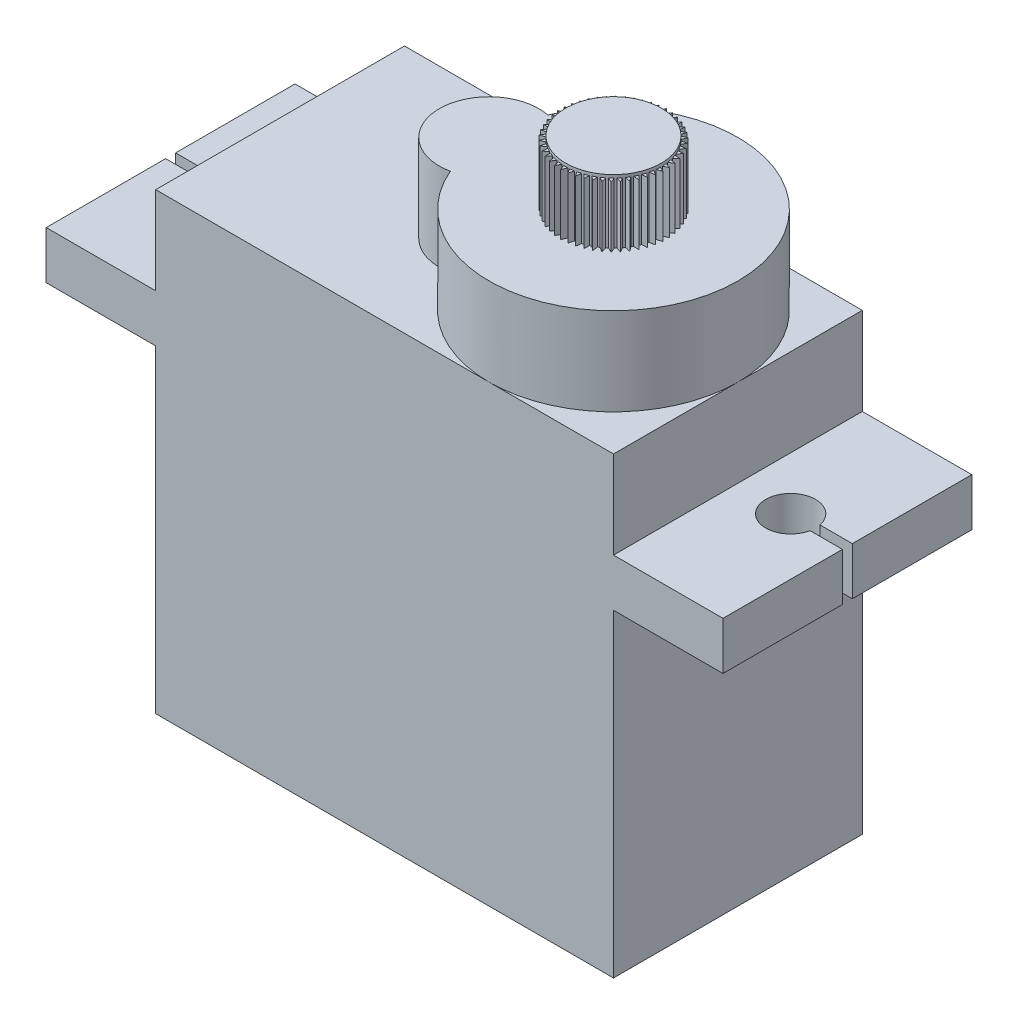
from build123d import *

# Parameters (mm, degrees)
SKETCH2_W           = 23
SKETCH2_H           = 12.5
BOSS_EXTRUDE1_DEPTH = 16
BOSS_EXTRUDE2_DEPTH = 2.4
SKETCH4_W           = 23
SKETCH4_H           = 12.5
BOSS_EXTRUDE3_DEPTH = 4.4
SKETCH5_R           = 1.25
CUT_EXTRUDE1_DEPTH  = 4.4
SKETCH6_W           = 3.848237884
SKETCH6_H           = 0.5
CUT_EXTRUDE2_DEPTH  = 4.4
SKETCH7_R           = 6.25
BOSS_EXTRUDE4_DEPTH = 4.4
SKETCH8_R           = 2.5
BOSS_EXTRUDE5_DEPTH = 4.4
SKETCH9_R           = 2.4
BOSS_EXTRUDE6_DEPTH = 3.2
BOSS_EXTRUDE7_DEPTH = 3.05
CIRPATTERN1_COUNT   = 50


with BuildPart() as part:
    # Sketch2 → Boss-Extrude1 (new body)
    with BuildSketch(Plane(origin=(0, 0, 0), x_dir=(1, 0, 0), z_dir=(0, 1, 0))):
        Rectangle(SKETCH2_W, SKETCH2_H)
    extrude(amount=BOSS_EXTRUDE1_DEPTH)

    # Sketch3 → Boss-Extrude2 (add)
    with BuildSketch(Plane(origin=(0, 16, 0), x_dir=(1, 0, 0), z_dir=(0, 1, 0))):
        Polygon((-11.5, 6.25), (-17, 6.25), (-17, -6.25), (-11.5, -6.25), (11.5, -6.25), (17, -6.25), (17, 6.25), (11.5, 6.25), align=None)
    extrude(amount=BOSS_EXTRUDE2_DEPTH)

    # Sketch4 → Boss-Extrude3 (add)
    with BuildSketch(Plane(origin=(0, 18.4, 0), x_dir=(1, 0, 0), z_dir=(0, 1, 0))):
        Rectangle(SKETCH4_W, SKETCH4_H)
    extrude(amount=BOSS_EXTRUDE3_DEPTH)

    # Sketch5 → Cut-Extrude1 (cut)
    with BuildSketch(Plane(origin=(0, 18.4, 0), x_dir=(1, 0, 0), z_dir=(0, 1, 0))):
        with Locations((-14.15, 0)):
            Circle(SKETCH5_R)
    cut_extrude1 = extrude(amount=-CUT_EXTRUDE1_DEPTH, mode=Mode.SUBTRACT)

    # Mirror1: Cut-Extrude1 across plane
    add(cut_extrude1.mirror(Plane(origin=(0, 0, 0), x_dir=(0, 0, 1), z_dir=(1, 0, 0))), mode=Mode.SUBTRACT)

    # Sketch6 → Cut-Extrude2 (cut)
    with BuildSketch(Plane(origin=(0, 18.4, 0), x_dir=(1, 0, 0), z_dir=(0, 1, 0))):
        with Locations((-15.4, 0)):
            Rectangle(SKETCH6_W, SKETCH6_H)
    cut_extrude2 = extrude(amount=-CUT_EXTRUDE2_DEPTH, mode=Mode.SUBTRACT)

    # Mirror2: Cut-Extrude2 across plane
    add(cut_extrude2.mirror(Plane(origin=(0, 0, 0), x_dir=(0, 0, 1), z_dir=(1, 0, 0))), mode=Mode.SUBTRACT)

    # Sketch7 → Boss-Extrude4 (add)
    with BuildSketch(Plane(origin=(0, 22.8, 0), x_dir=(1, 0, 0), z_dir=(0, 1, 0))):
        with Locations((5.25, 0)):
            Circle(SKETCH7_R)
    extrude(amount=BOSS_EXTRUDE4_DEPTH)

    # Sketch8 → Boss-Extrude5 (add)
    with BuildSketch(Plane(origin=(0, 22.8, 0), x_dir=(1, 0, 0), z_dir=(0, 1, 0))):
        with Locations((-1, 0)):
            Circle(SKETCH8_R)
    extrude(amount=BOSS_EXTRUDE5_DEPTH)

    # Sketch9 → Boss-Extrude6 (add)
    with BuildSketch(Plane(origin=(0, 27.2, 0), x_dir=(1, 0, 0), z_dir=(0, 1, 0))):
        with Locations((5.25, 0)):
            Circle(SKETCH9_R)
    extrude(amount=BOSS_EXTRUDE6_DEPTH)

    # Sketch10 → Boss-Extrude7 (add)
    with BuildSketch(Plane(origin=(0, 27.2, 0), x_dir=(1, 0, 0), z_dir=(0, 1, 0))):
        Polygon((5.35, 2.397915762), (5.25, 2.651588341), (5.15, 2.397915762), (5.25, 2.297915762), align=None)
    boss_extrude7 = extrude(amount=BOSS_EXTRUDE7_DEPTH)

    # CirPattern1: Boss-Extrude7 ×50 about axis
    cirpattern1_axis = Axis((5.25, 0, 0), (0, 1, 0))
    for i in range(1, CIRPATTERN1_COUNT):
        add(boss_extrude7.rotate(cirpattern1_axis, i * 360 / CIRPATTERN1_COUNT))


solid = part.part
